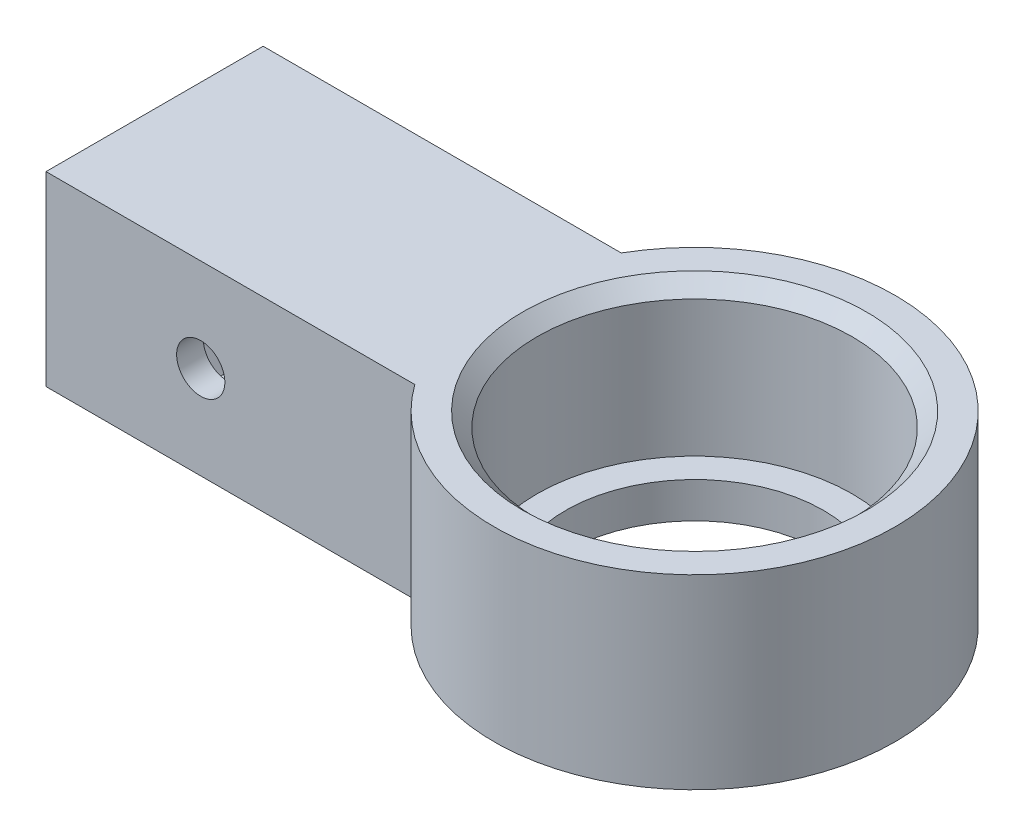
from build123d import *

# Parameters (mm, degrees)
ESBO_O2_R                = 11
RESSALTO_EXTRUS_O1_DEPTH = 13
ESBO_O3_W                = 7
ESBO_O3_H                = 7
CORTE_EXTRUS_O1_DEPTH    = 26
CORTE_EXTRUS_O2_DEPTH    = 2.8
ESBO_O10_R               = 1.683661958
CORTE_EXTRUS_O3_DEPTH    = 2.8
ESBO_O11_R               = 11
ESBO_O11_R_2             = 9
RESSALTO_EXTRUS_O2_DEPTH = 2.5
CHANFRO1_SIZE            = 1


with BuildPart() as part:
    # Esboço2 → Ressalto-extrusão1 (new body)
    with BuildSketch(Plane(origin=(0, 0, 0), x_dir=(1, 0, 0), z_dir=(0, 1, 0))):
        with BuildLine():
            Line((-12.124355653, 7), (-37.124355653, 7))
            Line((-37.124355653, 7), (-37.124355653, -8.161034979))
            Line((-37.124355653, -8.161034979), (-11.375302548, -8.161034979))
            ThreePointArc((-11.375302548, -8.161034979), (13.982944229, 0.690847808), (-12.124355653, 7))
        make_face()
        Circle(ESBO_O2_R, mode=Mode.SUBTRACT)
    extrude(amount=RESSALTO_EXTRUS_O1_DEPTH)

    # Esboço3 → Corte-extrusão1 (cut)
    with BuildSketch(Plane.ZY.offset(37.124355653)):
        with Locations((0, 6.5)):
            Rectangle(ESBO_O3_W, ESBO_O3_H)
    extrude(amount=-CORTE_EXTRUS_O1_DEPTH, mode=Mode.SUBTRACT)

    # Esboço7 → Corte-extrusão2 (cut)
    with BuildSketch(Plane(origin=(0, 0, 3.5), x_dir=(-1, 0, 0), z_dir=(0, 0, -1))):
        Polygon((23.145814462, 6.5), (24.733527702, 3.75), (27.908954183, 3.75), (29.496667423, 6.5), (27.908954183, 9.25), (24.733527702, 9.25), align=None)
    extrude(amount=-CORTE_EXTRUS_O2_DEPTH, mode=Mode.SUBTRACT)

    # Esboço10 → Corte-extrusão3 (cut)
    with BuildSketch(Plane(origin=(0, 0, 6.3), x_dir=(-1, 0, 0), z_dir=(0, 0, -1))):
        with Locations((26.321240942, 6.5)):
            Circle(ESBO_O10_R)
    extrude(amount=-CORTE_EXTRUS_O3_DEPTH, mode=Mode.SUBTRACT)

    # Esboço11 → Ressalto-extrusão2 (add)
    with BuildSketch(Plane.XZ):
        Circle(ESBO_O11_R)
        Circle(ESBO_O11_R_2, mode=Mode.SUBTRACT)
    extrude(amount=-RESSALTO_EXTRUS_O2_DEPTH)

    # Chanfro1
    chanfro1_edges = [part.edges().sort_by_distance(p)[0] for p in [
        (-11, 13, 0),
    ]]
    chamfer(chanfro1_edges, length=CHANFRO1_SIZE)


solid = part.part
